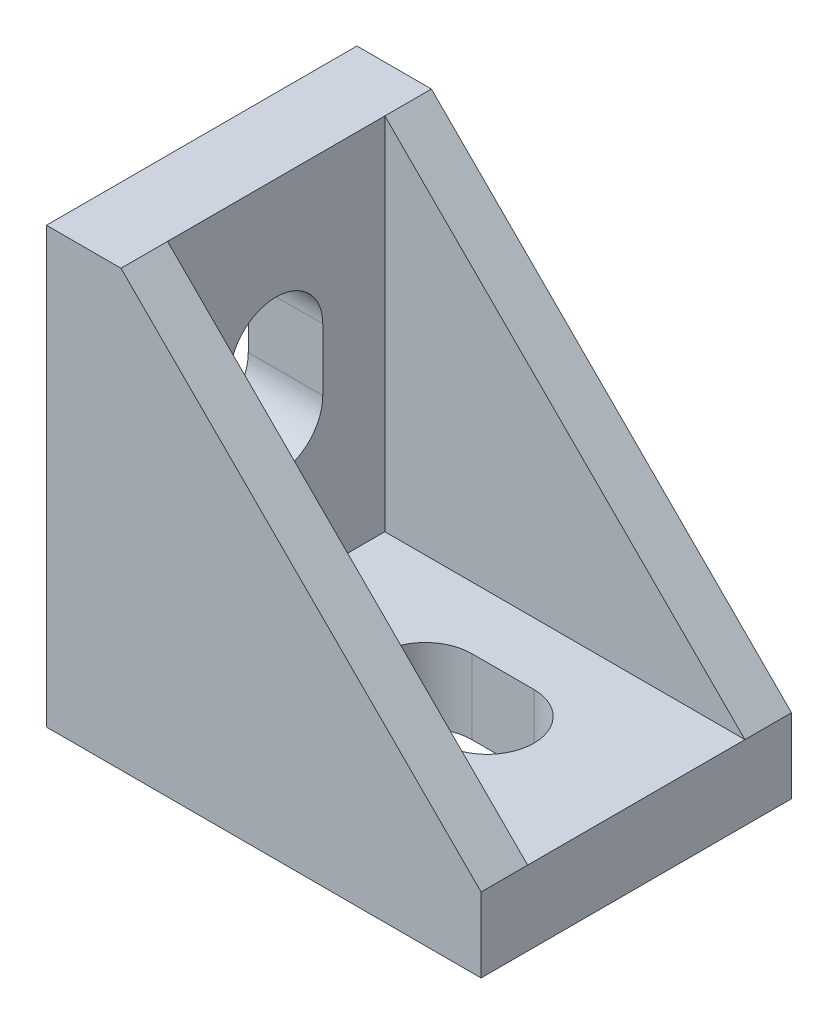
from build123d import *

# Parameters (mm, degrees)
SKETCH1_W           = 28
SKETCH1_H           = 20
BOSS_EXTRUDE1_DEPTH = 4.8
SKETCH2_W           = 20
SKETCH2_H           = 28
BOSS_EXTRUDE2_DEPTH = 4.8
CUT_EXTRUDE1_DEPTH  = 5.8
CUT_EXTRUDE2_DEPTH  = 5.8
BOSS_EXTRUDE3_DEPTH = 3
BOSS_EXTRUDE4_DEPTH = 3


with BuildPart() as part:
    # Sketch1 → Boss-Extrude1 (new body)
    with BuildSketch(Plane(origin=(0, 0, 0), x_dir=(1, 0, 0), z_dir=(0, 1, 0))):
        Rectangle(SKETCH1_W, SKETCH1_H)
    extrude(amount=BOSS_EXTRUDE1_DEPTH)

    # Sketch2 → Boss-Extrude2 (add)
    with BuildSketch(Plane.ZY.offset(14)):
        with Locations((0, 14)):
            Rectangle(SKETCH2_W, SKETCH2_H)
    extrude(amount=-BOSS_EXTRUDE2_DEPTH)

    # Sketch3 → Cut-Extrude1 (cut, through all)
    with BuildSketch(Plane(origin=(-9.2, 0, 0), x_dir=(0, 0, -1), z_dir=(1, 0, 0))):
        with BuildLine():
            Line((3, 18.4), (3, 14.4))
            ThreePointArc((3, 14.4), (0, 11.4), (-3, 14.4))
            Line((-3, 14.4), (-3, 18.4))
            ThreePointArc((-3, 18.4), (0, 21.4), (3, 18.4))
        make_face()
    extrude(amount=-CUT_EXTRUDE1_DEPTH, mode=Mode.SUBTRACT)

    # Sketch4 → Cut-Extrude2 (cut, through all)
    with BuildSketch(Plane(origin=(0, 4.8, 0), x_dir=(1, 0, 0), z_dir=(0, 1, 0))):
        with BuildLine():
            Line((0.4, 3), (4.4, 3))
            ThreePointArc((4.4, 3), (7.4, 0), (4.4, -3))
            Line((4.4, -3), (0.4, -3))
            ThreePointArc((0.4, -3), (-2.6, 0), (0.4, 3))
        make_face()
    extrude(amount=-CUT_EXTRUDE2_DEPTH, mode=Mode.SUBTRACT)

    # Sketch5 → Boss-Extrude3 (add)
    with BuildSketch(Plane.XY.offset(10)):
        Polygon((-9.2, 28), (14, 4.8), (-9.2, 4.8), align=None)
    extrude(amount=-BOSS_EXTRUDE3_DEPTH)

    # Sketch6 → Boss-Extrude4 (add)
    with BuildSketch(Plane(origin=(0, 0, -10), x_dir=(-1, 0, 0), z_dir=(0, 0, -1))):
        Polygon((9.2, 28), (9.2, 4.8), (-14, 4.8), align=None)
    extrude(amount=-BOSS_EXTRUDE4_DEPTH)


solid = part.part
